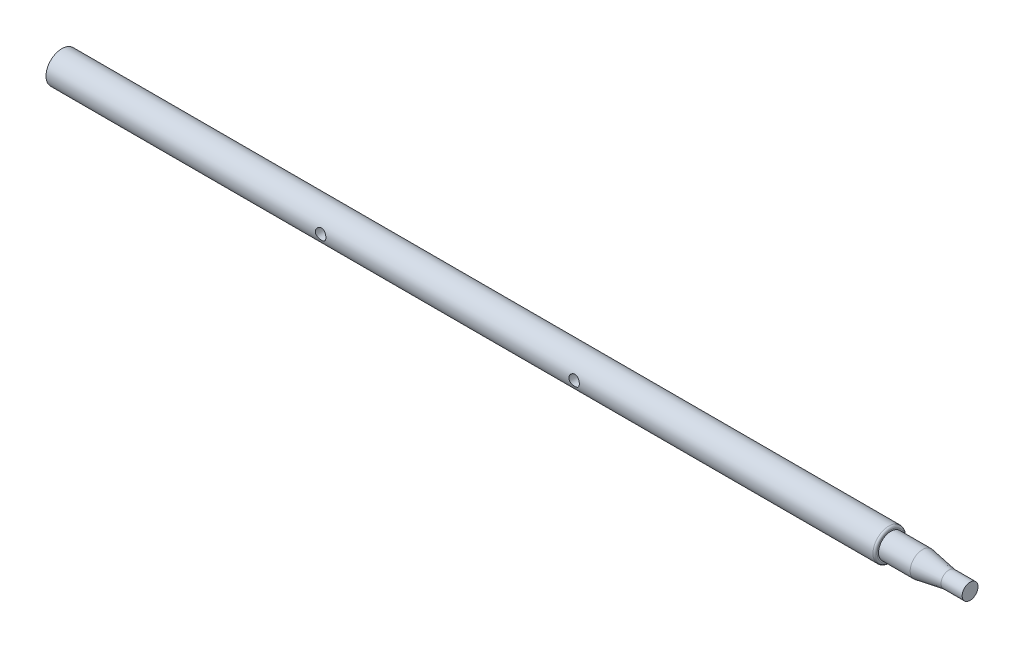
from build123d import *

# Parameters (mm, degrees)
FILLET1_R               = 2
SKETCH2_R               = 5
CUT_EXTRUDE1_DEPTH      = 16
CUT_EXTRUDE1_DEPTH_BACK = 16


with BuildPart() as part:
    # Sketch1 → Revolve1 (revolve)
    with BuildSketch(Plane.XY):
        Polygon((-782.772277228, 0), (-782.772277228, 15), (2.227722772, 15), (2.227722772, 11.732673267), (32.227722772, 11.732673267), (57.227722772, 7.5), (77.227722772, 7.5), (77.227722772, 0), align=None)
    revolve(axis=Axis((-782.772277228, 0, 0), (1, 0, 0)))

    # Fillet1
    fillet1_edges = [part.edges().sort_by_distance(p)[0] for p in [
        (2.227722772, -15, 0),
    ]]
    fillet(fillet1_edges, radius=FILLET1_R)

    # Sketch2 → Cut-Extrude1 (cut, two sides)
    with BuildSketch(Plane.XY) as cut_extrude1_sk:
        with Locations((-522.772277228, 0)):
            Circle(SKETCH2_R)
        with Locations((-282.772277228, 0)):
            Circle(SKETCH2_R)
    extrude(amount=CUT_EXTRUDE1_DEPTH, mode=Mode.SUBTRACT)
    extrude(cut_extrude1_sk.sketch, amount=-CUT_EXTRUDE1_DEPTH_BACK, mode=Mode.SUBTRACT)


solid = part.part
